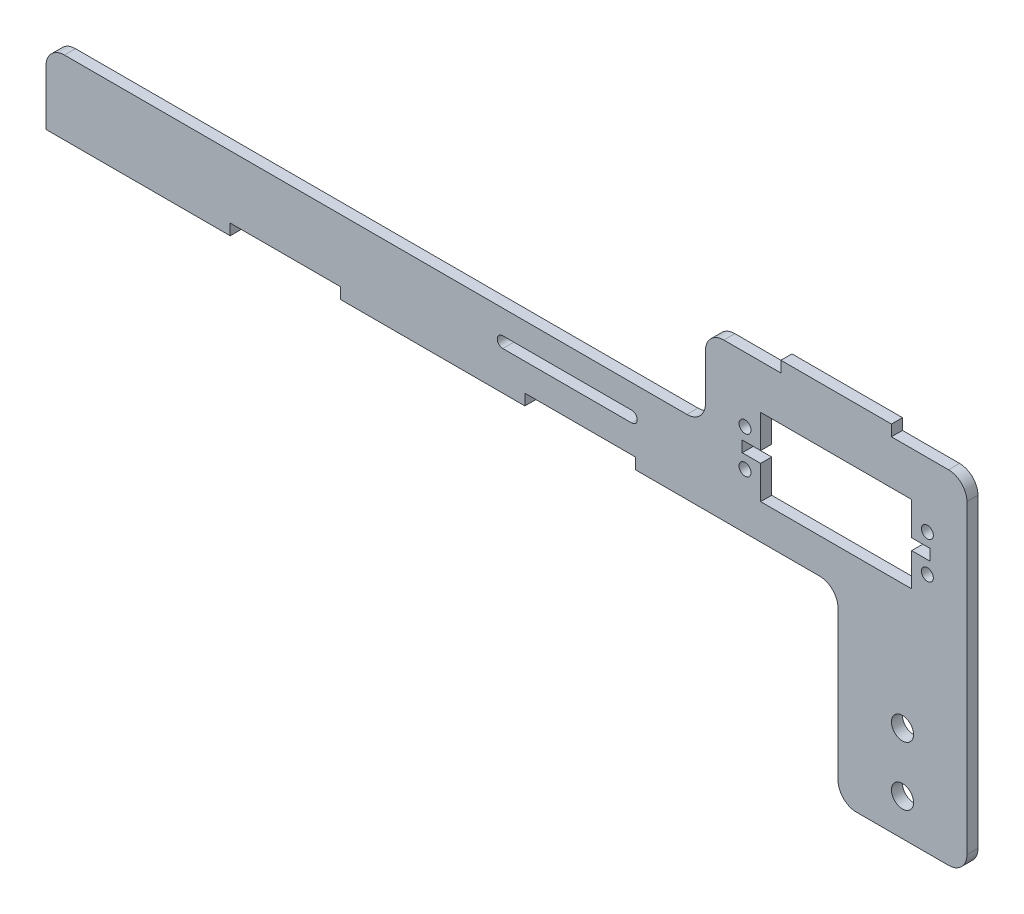
from build123d import *

# Parameters (mm, degrees)
ESBO_O1_R                = 3
ESBO_O1_R_2              = 1.625
ESBO_O1_W                = 30
ESBO_O1_H                = 3
RESSALTO_EXTRUS_O1_DEPTH = 3
FILETE1_R                = 5


with BuildPart() as part:
    # Esboço1 → Ressalto-extrusão1 (new body)
    with BuildSketch(Plane.XY):
        Polygon((160, -20), (215, -20), (215, -70.5), (250, -70.5), (250, -20), (250, 22.5), (229.5, 22.5), (199.5, 22.5), (179, 22.5), (179, 0), (0, 0), (0, -20), (50, -20), (50, -17), (80, -17), (80, -20), (130, -20), (130, -17), (160, -17), align=None)
        with Locations((232.5, -60.5)):
            Circle(ESBO_O1_R, mode=Mode.SUBTRACT)
        with Locations((232.5, -44.5)):
            Circle(ESBO_O1_R, mode=Mode.SUBTRACT)
        with BuildLine():
            ThreePointArc((124, -9.5), (122.5, -8), (124, -6.5))
            Line((124, -6.5), (159, -6.5))
            ThreePointArc((159, -6.5), (160.5, -8), (159, -9.5))
            Line((159, -9.5), (124, -9.5))
        make_face(mode=Mode.SUBTRACT)
        with Locations((189.75, -5)):
            Circle(ESBO_O1_R_2, mode=Mode.SUBTRACT)
        Polygon((194, 1.5), (194, 10.5), (235, 10.5), (235, 1.5), (240, 1.5), (240, -1.5), (235, -1.5), (235, -10.5), (194, -10.5), (194, -1.5), (189, -1.5), (189, 1.5), align=None, mode=Mode.SUBTRACT)
        with Locations((239.25, -5)):
            Circle(ESBO_O1_R_2, mode=Mode.SUBTRACT)
        with Locations((189.75, 5)):
            Circle(ESBO_O1_R_2, mode=Mode.SUBTRACT)
        with Locations((239.25, 5)):
            Circle(ESBO_O1_R_2, mode=Mode.SUBTRACT)
        with Locations((214.5, 24)):
            Rectangle(ESBO_O1_W, ESBO_O1_H)
    extrude(amount=RESSALTO_EXTRUS_O1_DEPTH)

    # Filete1
    filete1_edges = [part.edges().sort_by_distance(p)[0] for p in [
        (250, 22.5, 1.5),
        (250, -70.5, 1.5),
        (215, -70.5, 1.5),
        (215, -20, 1.5),
        (0, 0, 1.5),
        (179, 0, 1.5),
        (179, 22.5, 1.5),
    ]]
    fillet(filete1_edges, radius=FILETE1_R)


solid = part.part
